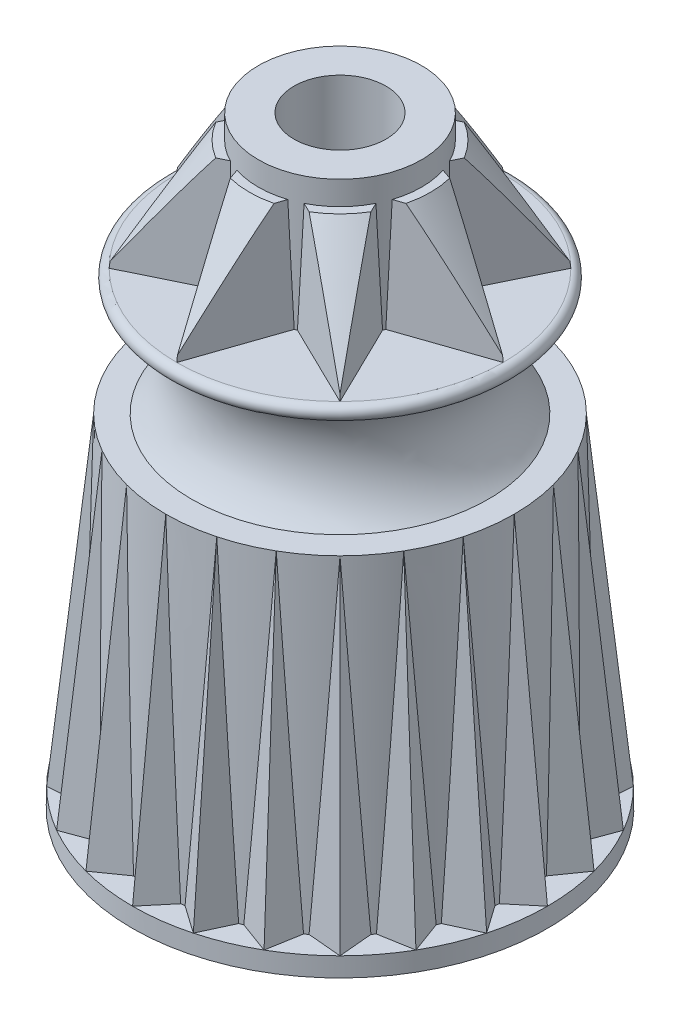
from build123d import *
from build123d.topology import SkipClean

# Parameters (mm, degrees)
SKETCH1_R           = 8.89
BOSS_EXTRUDE1_DEPTH = 0.8128
BOSS_EXTRUDE1_TAPER = 1
SKETCH2_R           = 7.4549
SKETCH3_R           = 7.8105
CIRPATTERN1_COUNT   = 24
SKETCH8_R           = 3.4925
BOSS_EXTRUDE2_DEPTH = 5.7658
SKETCH9_R           = 1.9685
CUT_EXTRUDE1_DEPTH  = 26.7810001
BOSS_EXTRUDE3_DEPTH = 4.7498
BOSS_EXTRUDE3_TAPER = 2
CIRPATTERN2_COUNT   = 8
FILLET1_R           = 0.762
RIB1_REACH          = 26.003
SKETCH13_WALLS_W    = 1.016
SKETCH13_WALLS_H    = 54.050278555
RIB1_DRAFT_ANGLE    = 1
FILLET2_R           = 0.508


with BuildPart() as part:
    # Sketch1 → Boss-Extrude1 (new body)
    with BuildSketch(Plane(origin=(0, 0, 0), x_dir=(1, 0, 0), z_dir=(0, 1, 0))):
        Circle(SKETCH1_R)
    extrude(amount=BOSS_EXTRUDE1_DEPTH, taper=BOSS_EXTRUDE1_TAPER)

    # Sketch2 → Loft1 section 0
    with BuildSketch(Plane(origin=(0, 14.6304, 0), x_dir=(1, 0, 0), z_dir=(0, 1, 0))):
        Circle(SKETCH2_R)
    # Sketch3 → Loft1 section 1
    with BuildSketch(Plane(origin=(0, 0.8128, 0), x_dir=(1, 0, 0), z_dir=(0, 1, 0))):
        Circle(SKETCH3_R)
    loft()

    # Sweep1: sweep along a path in Sketch4
    with SkipClean():  # keep this step's faces unmerged: merging them makes the solid invalid here
        with BuildLine(Plane(origin=(0, 0, 0), x_dir=(0, 0, -1), z_dir=(1, 0, 0))) as sweep1_path:
            Line((-8.875812523, 0.8128), (-7.4549, 14.6304))
        # Sketch5 → Sweep1 (sweep)
        with BuildSketch(Plane(origin=(0, 0.8128, 8.875812523), x_dir=(1, 0, 0), z_dir=(0, 0.994754201, -0.102294082))):
            Polygon((0, 0), (1.278787838, 1.524), (-1.278787838, 1.524), align=None)
        sweep1 = sweep(path=sweep1_path.line)

    # CirPattern1: Sweep1 ×24 about axis
    cirpattern1_axis = Axis((0, 0, 0), (0, 1, 0))
    for i in range(1, CIRPATTERN1_COUNT):
        add(sweep1.rotate(cirpattern1_axis, i * 360 / CIRPATTERN1_COUNT))

    # Sketch7 → Revolve1 (revolve)
    with BuildSketch(Plane(origin=(0, 0, 0), x_dir=(0, 0, -1), z_dir=(1, 0, 0))):
        with BuildLine():
            Line((0, 20.0152), (6.985, 20.0152))
            ThreePointArc((6.985, 20.0152), (7.3025, 19.6977), (6.985, 19.3802))
            Line((6.985, 19.3802), (6.35, 19.3802))
            ThreePointArc((6.35, 19.3802), (5.3467, 17.0053), (6.35, 14.6304))
            Line((6.35, 14.6304), (0, 14.6304))
            Line((0, 14.6304), (0, 20.0152))
        make_face()
    revolve(axis=Axis((0, 14.6304, 0), (0, 1, 0)))

    # Sketch8 → Boss-Extrude2 (add)
    with BuildSketch(Plane(origin=(0, 20.0152, 0), x_dir=(1, 0, 0), z_dir=(0, 1, 0))):
        with Locations(Location((0, 0, 0), (0, 0, 270))):  # turned: the seam where the file's is
            Circle(SKETCH8_R)
    extrude(amount=BOSS_EXTRUDE2_DEPTH)

    # Sketch9 → Cut-Extrude1 (cut, through all)
    with BuildSketch(Plane(origin=(0, 25.781, 0), x_dir=(1, 0, 0), z_dir=(0, 1, 0))):
        with Locations(Location((0, 0, 0), (0, 0, 270))):  # turned: the seam where the file's is
            Circle(SKETCH9_R)
    extrude(amount=-CUT_EXTRUDE1_DEPTH, mode=Mode.SUBTRACT)

    # Sketch10 → Boss-Extrude3 (add)
    with BuildSketch(Plane(origin=(0, 20.0152, 0), x_dir=(1, 0, 0), z_dir=(0, 1, 0))):
        Polygon((0, -6.985), (1.56635116, -2.435985924), (-1.56635116, -2.435985924), align=None)
    boss_extrude3 = extrude(amount=BOSS_EXTRUDE3_DEPTH, taper=BOSS_EXTRUDE3_TAPER)

    # CirPattern2: Boss-Extrude3 ×8 about axis
    cirpattern2_axis = Axis((0, 0, 0), (0, 1, 0))
    for i in range(1, CIRPATTERN2_COUNT):
        add(boss_extrude3.rotate(cirpattern2_axis, i * 360 / CIRPATTERN2_COUNT))

    # Sketch11 → Cut-Revolve1 (revolve, cut)
    with BuildSketch(Plane(origin=(0, 0, 0), x_dir=(0, 0, -1), z_dir=(1, 0, 0)), mode=Mode.PRIVATE) as cut_revolve1_sk:
        Polygon((3.4925, 24.765), (3.4925, 25.781), (7.465911085, 25.781), (7.465911085, 20.267751363), (6.957911085, 20.267751363), (3.8735, 24.765), align=None)
    revolve(cut_revolve1_sk.sketch.rotate(Axis((0, 61.440281733, 0), (0, -1, 0)), 18.131332636), axis=Axis((0, 61.440281733, 0), (0, -1, 0)), mode=Mode.SUBTRACT)  # turned: the seam where the file's is

    # Sketch12 → Cut-Revolve2 (revolve, cut)
    with BuildSketch(Plane(origin=(0, 0, 0), x_dir=(0, 0, -1), z_dir=(1, 0, 0))):
        with BuildLine():
            Line((2.921, 0), (3.194108928, 15.6464))
            Line((3.194108928, 15.6464), (4.549542973, 15.6464))
            ThreePointArc((4.549542973, 15.6464), (4.990447661, 14.708323353), (5.641733851, 13.901966707))
            Line((5.641733851, 13.901966707), (5.889715871, 13.901966707))
            Line((5.889715871, 13.901966707), (6.270518716, 2.9972))
            Line((6.270518716, 2.9972), (6.448427093, 2.9972))
            Line((6.448427093, 2.9972), (6.491002495, 1.778))
            Line((6.491002495, 1.778), (6.668910872, 1.778))
            Line((6.668910872, 1.778), (6.731, 0))
            Line((6.731, 0), (6.731, -2.54))
            Line((6.731, -2.54), (2.921, -2.54))
            Line((2.921, -2.54), (2.921, 0))
        make_face()
    revolve(axis=Axis((0, 0, 0), (0, 1, 0)), mode=Mode.SUBTRACT)

    # Fillet1
    fillet1_edges = [part.edges().sort_by_distance(p)[0] for p in [
        (0, 0, 6.731),
    ]]
    fillet(fillet1_edges, radius=FILLET1_R)

    # Sketch13 walls → Rib1 (add, up to next)
    with BuildSketch(Plane.XZ.offset(-1.778), mode=Mode.PRIVATE) as rib1_sk1:
        with Locations((0, -4.468863318)):
            Rectangle(SKETCH13_WALLS_W, SKETCH13_WALLS_H)
    rib1_tool1 = extrude(rib1_sk1.sketch, amount=-RIB1_REACH, mode=Mode.PRIVATE) - part.part
    add(rib1_tool1.solids().sort_by_distance((0, 1.778, -4.468863317))[0])
    # Sketch13 walls → Rib1 (add, up to next)
    with BuildSketch(Plane.XZ.offset(-1.778), mode=Mode.PRIVATE) as rib1_sk2:
        with Locations((0, 4.468863318)):
            Rectangle(SKETCH13_WALLS_W, SKETCH13_WALLS_H)
    rib1_tool2 = extrude(rib1_sk2.sketch, amount=-RIB1_REACH, mode=Mode.PRIVATE) - part.part
    add(rib1_tool2.solids().sort_by_distance((0, 1.778, 4.468863317))[0])

    # Rib1 draft
    rib1_draft_faces = [part.faces().sort_by_distance(p)[0] for p in [
        (0.508, 2.032, -4.468863318),
        (-0.508, 2.032, -4.468863318),
        (0.508, 2.032, 4.468863318),
        (-0.508, 2.032, 4.468863318),
    ]]
    draft(rib1_draft_faces, Plane(origin=(0, 1.778, -4.468863317), x_dir=(1, 0, 0), z_dir=(0, -1, 0)), RIB1_DRAFT_ANGLE)

    # Fillet2
    fillet2_edges = [part.edges().sort_by_distance(p)[0] for p in [
        (0.508, 1.778, 4.689545246),
        (-0.508, 1.778, 4.689545246),
        (-0.508, 1.778, -4.689545246),
        (0.508, 1.778, -4.689545246),
    ]]
    fillet(fillet2_edges, radius=FILLET2_R)


solid = part.part
